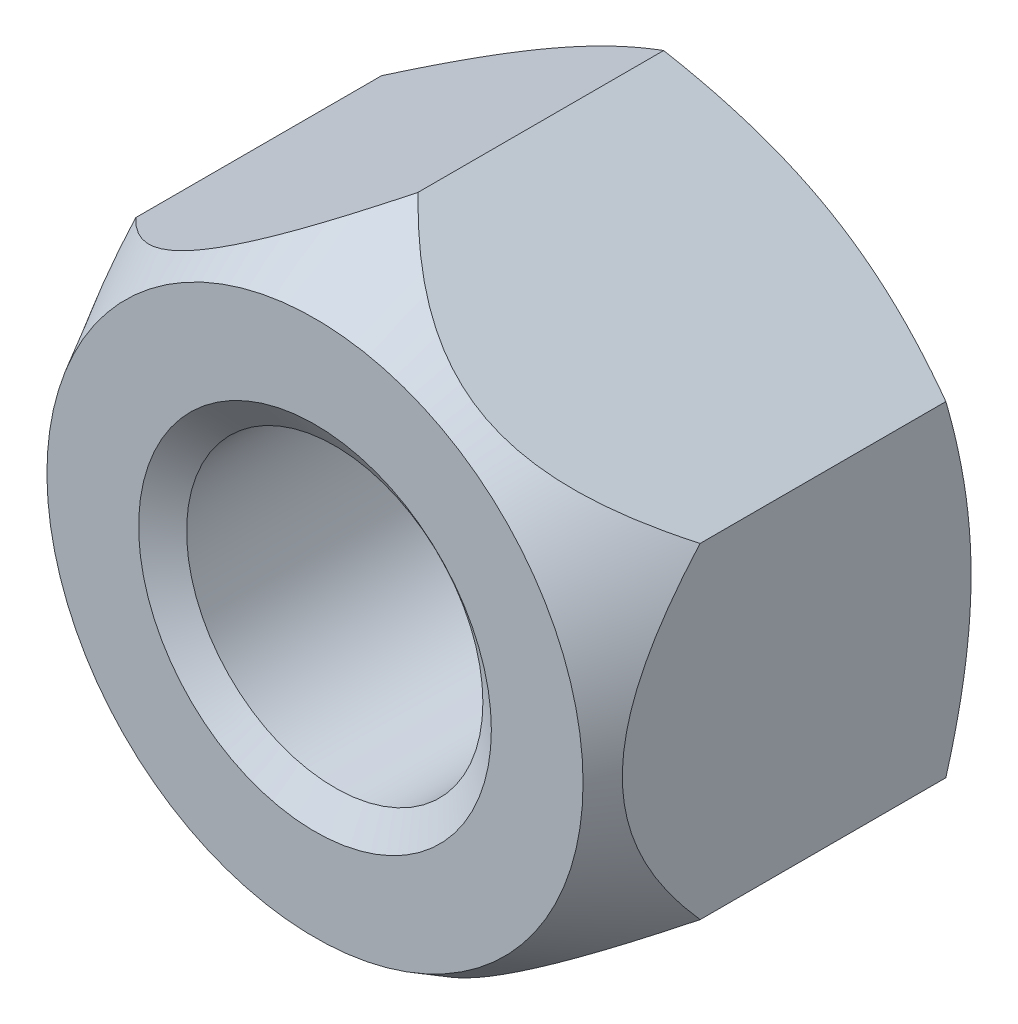
from build123d import *

# Parameters (mm, degrees)
BASENUTSKE_R  = 2.1
BASENUT_DEPTH = 5.3


with BuildPart() as part:
    # BaseNutSke → BaseNut (new body)
    with BuildSketch(Plane.XY):
        Polygon((4, 2.309401077), (4, -2.309401077), (0, -4.618802154), (-4, -2.309401077), (-4, 2.309401077), (0, 4.618802154), align=None)
        Circle(BASENUTSKE_R, mode=Mode.SUBTRACT)
    extrude(amount=-BASENUT_DEPTH)

    # Sketch3 → Double-Chamfer (revolve, cut)
    with BuildSketch(Plane(origin=(0, 0, 0), x_dir=(0, 0, -1), z_dir=(1, 0, 0))):
        Polygon((5.3, 4), (4.94273441, 4.618802154), (4.94273441, 14.618802154), (15.3, 14.618802154), (15.3, 4), align=None)
        Polygon((1.46, 14.618802154), (-10, 14.618802154), (-10, 3.8), (0, 3.8), (1.46, 4.618802154), align=None)
    revolve(axis=Axis((0, 0, 0), (0, 0, -1)), mode=Mode.SUBTRACT)

    # Sketch5 → EndChamfer (revolve, cut)
    with BuildSketch(Plane(origin=(0, 0, 0), x_dir=(0, 0, -1), z_dir=(1, 0, 0))):
        Polygon((5.2746, 2.5), (4.966508683, 2.06), (5.3254, 2.06), (5.3254, 2.5), align=None)
        Polygon((-0.0508, 2.5), (0, 2.5), (0.308091317, 2.06), (-0.0508, 2.06), align=None)
    revolve(axis=Axis((0, 0, -25.037505729), (0, 0, -1)), mode=Mode.SUBTRACT)


solid = part.part
